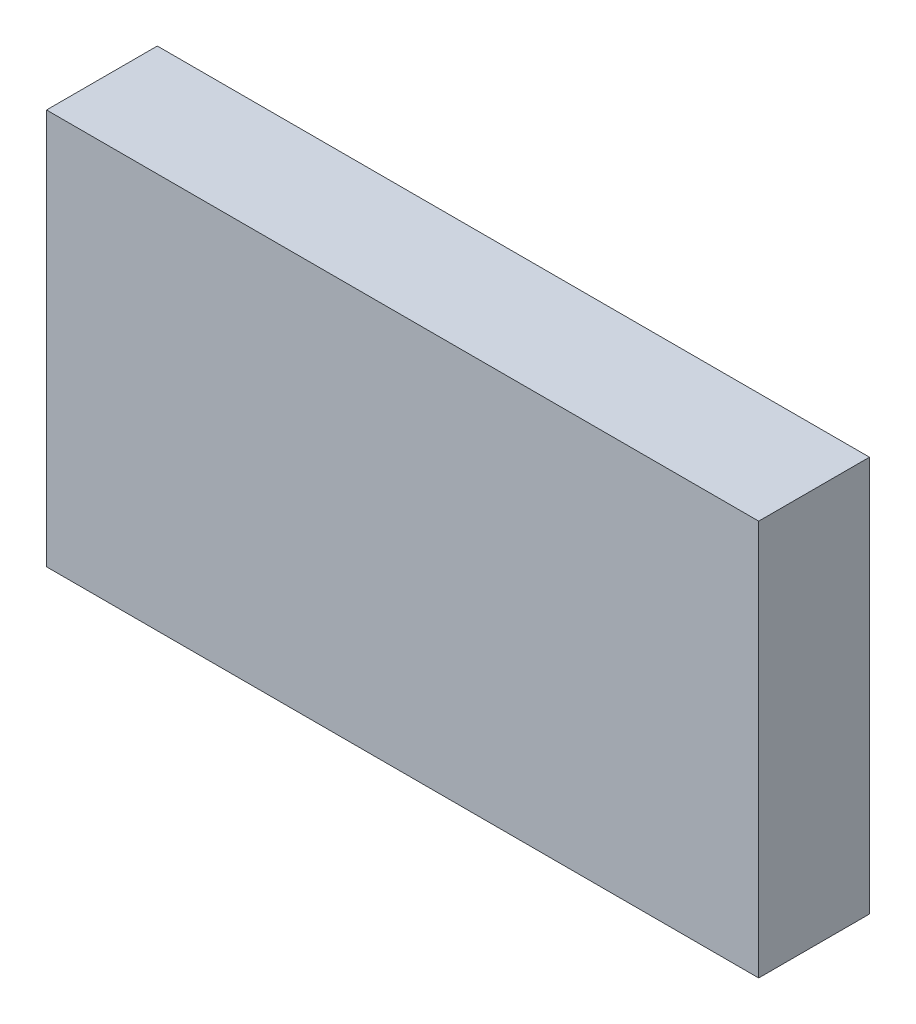
from build123d import *

# Parameters (mm, degrees)
SKETCH2_W      = 114.3
SKETCH2_H      = 63.5
EXTRUDE1_DEPTH = 17.78


with BuildPart() as part:
    # Sketch2 → Extrude1 (new body)
    with BuildSketch(Plane.XY):
        with Locations((11574.991666666, -5688.0125)):
            Rectangle(SKETCH2_W, SKETCH2_H)
    extrude(amount=-EXTRUDE1_DEPTH)


solid = part.part
